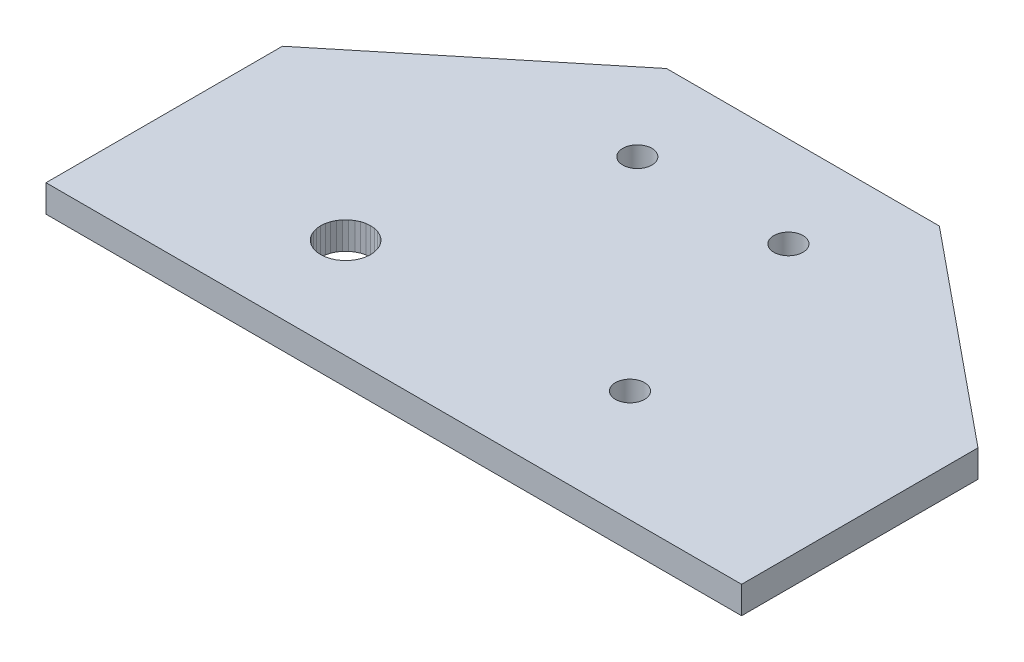
from build123d import *

# Parameters (mm, degrees)
BOSS_EXTRUDE1_DEPTH  = 3.000000492
CUT_EXTRUDE1_DEPTH   = 4.000000492
BOSS_EXTRUDE3_DEPTH  = 4.999998957
SKETCH14_R           = 2.583283714
CUT_EXTRUDE6_DEPTH   = 8
M3_CLEARANCE_HOLE2_D = 3.2
M3_CLEARANCE_HOLE3_D = 3.2


with BuildPart() as part:
    # Sketch1 → Boss-Extrude1 (new body)
    with BuildSketch(Plane(origin=(0, 13.000000268, 0), x_dir=(1, 0, 0), z_dir=(0, 1, 0))):
        Polygon((0, -45.000001788), (76.499998569, -45.000001788), (76.499998569, -19.000001252), (53.249999881, 0), (23.250000551, 0), (0, -19.000001252), align=None)
    extrude(amount=-BOSS_EXTRUDE1_DEPTH)

    # Sketch2 → Cut-Extrude1 (cut, through all)
    with BuildSketch(Plane.XZ.offset(-9.999999776)):
        Polygon((24.331569672, 35.374999046), (24.056620896, 35.767666996), (23.717667907, 36.106623709), (23.324999958, 36.381572485), (22.890556604, 36.584153771), (22.427532822, 36.70822084), (21.949999034, 36.74999997), (21.472468972, 36.70822084), (21.00944519, 36.584153771), (20.574999973, 36.381572485), (20.182333887, 36.106623709), (19.843377173, 35.767666996), (19.56843026, 35.374999046), (19.365845248, 34.940555692), (19.241780043, 34.47753191), (19.200000912, 34.000001848), (19.241780043, 33.52246806), (19.365845248, 33.059444278), (19.56843026, 32.625000924), (19.843377173, 32.2323367), (20.182333887, 31.893379986), (20.574999973, 31.618431211), (21.00944519, 31.415846199), (21.472468972, 31.291779131), (21.949999034, 31.25), (22.427532822, 31.291779131), (22.890556604, 31.415846199), (23.324999958, 31.618431211), (23.717667907, 31.893379986), (24.056620896, 32.2323367), (24.331569672, 32.625000924), (24.534154683, 33.059444278), (24.658221751, 33.52246806), (24.700000882, 34.000001848), (24.658221751, 34.47753191), (24.534154683, 34.940555692), align=None)
    extrude(amount=-CUT_EXTRUDE1_DEPTH, mode=Mode.SUBTRACT)

    # Sketch4 → Boss-Extrude3 (add)
    with BuildSketch(Plane(origin=(0, 13.000000268, 0), x_dir=(-1, 0, 0), z_dir=(0, 1, 0))):
        Polygon((-41.949994862, 10.347297415), (-41.919611394, 9.999999776), (-41.949994862, 9.652704), (-42.040225118, 9.315960109), (-42.18756035, 9.000001475), (-42.387522757, 8.714426309), (-42.634036392, 8.467912674), (-42.919609696, 8.267950267), (-43.235570192, 8.120615035), (-43.572314084, 8.030384779), (-43.919611722, 8.000001311), (-44.266905636, 8.030384779), (-44.603649527, 8.120615035), (-44.919610023, 8.267950267), (-45.205187052, 8.467912674), (-45.451700687, 8.714426309), (-45.651663095, 9.000001475), (-45.798994601, 9.315960109), (-45.889224857, 9.652704), (-45.91961205, 9.999999776), (-45.889224857, 10.347297415), (-45.798994601, 10.684041306), (-45.651663095, 10.99999994), (-45.451700687, 11.285575107), (-45.205187052, 11.532089673), (-44.919610023, 11.732051149), (-44.603649527, 11.87938638), (-44.266905636, 11.969616637), (-43.919611722, 12.000001036), (-43.572314084, 11.969616637), (-43.235570192, 11.87938638), (-42.919609696, 11.732051149), (-42.634036392, 11.532089673), (-42.387522757, 11.285575107), (-42.18756035, 10.99999994), (-42.040225118, 10.684041306), align=None)
    extrude(amount=BOSS_EXTRUDE3_DEPTH)

    # Sketch14 → Cut-Extrude6 (cut)
    with BuildSketch(Plane(origin=(0, 13.000000268, 0), x_dir=(1, 0, 0), z_dir=(0, 1, 0))):
        with Locations((43.972754788, -10.139500391)):
            Circle(SKETCH14_R)
    extrude(amount=CUT_EXTRUDE6_DEPTH, mode=Mode.SUBTRACT)

    # M3 Clearance Hole2 (through all)
    with Locations(Plane(origin=(0, 13.000000268, 0), x_dir=(1, 0, 0), z_dir=(0, 1, 0))):
        with Locations((30.040436258, -10.00628369), (46.656531008, -10.00628369)):
            Hole(M3_CLEARANCE_HOLE2_D / 2)

    # M3 Clearance Hole3 (through all)
    with Locations(Plane(origin=(0, 13.000000268, 0), x_dir=(1, 0, 0), z_dir=(0, 1, 0))):
        with Locations((51.953516863, -32.727697483)):
            Hole(M3_CLEARANCE_HOLE3_D / 2)


solid = part.part
